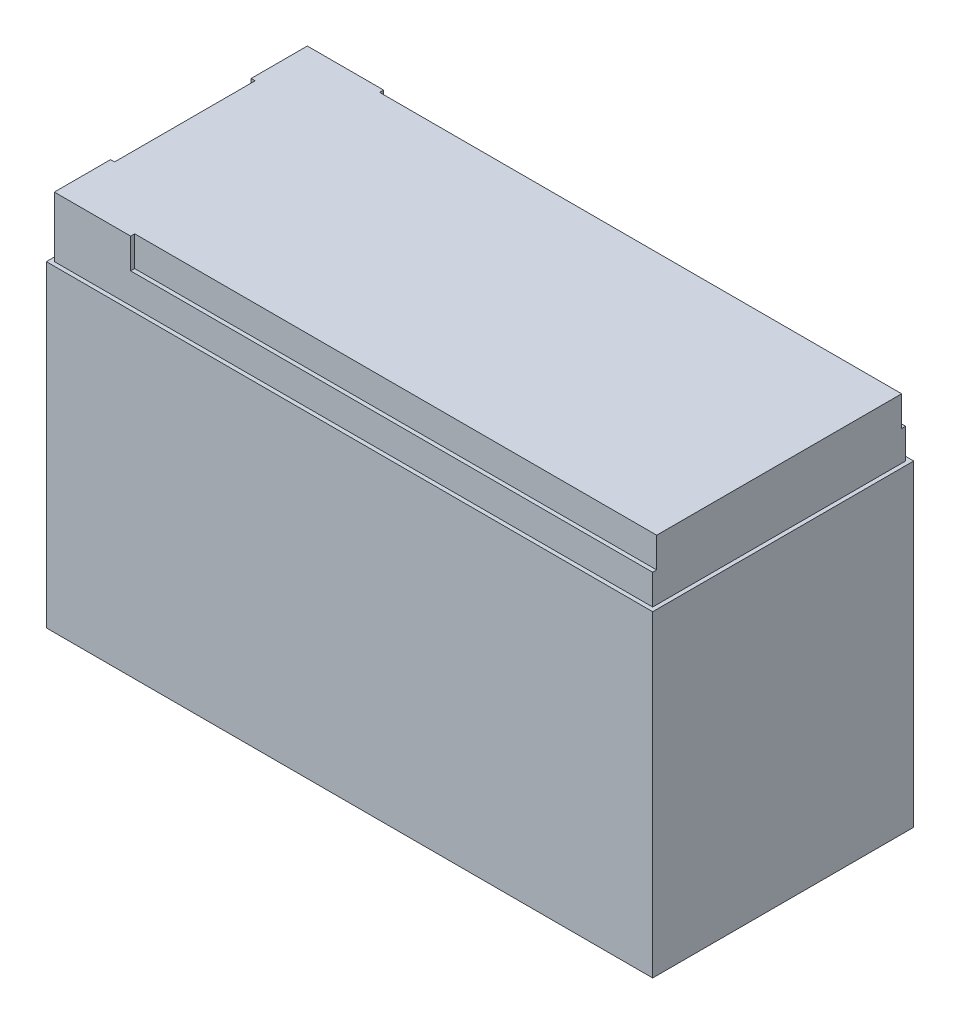
from build123d import *

# Parameters (mm, degrees)
SKETCH1_W           = 151
SKETCH1_H           = 65
BOSS_EXTRUDE1_DEPTH = 94
SKETCH2_W           = 151
SKETCH2_H           = 65
SKETCH2_W_2         = 149
SKETCH2_H_2         = 63
CUT_EXTRUDE1_DEPTH  = 15
SKETCH3_W           = 130
SKETCH3_H           = 1
CUT_EXTRUDE2_DEPTH  = 7.5
SKETCH4_W           = 1
SKETCH4_H           = 35
CUT_EXTRUDE3_DEPTH  = 7.5


with BuildPart() as part:
    # Sketch1 → Boss-Extrude1 (new body)
    with BuildSketch(Plane(origin=(0, 0, 0), x_dir=(1, 0, 0), z_dir=(0, 1, 0))):
        Rectangle(SKETCH1_W, SKETCH1_H)
    extrude(amount=BOSS_EXTRUDE1_DEPTH)

    # Sketch2 → Cut-Extrude1 (cut)
    with BuildSketch(Plane(origin=(0, 94, 0), x_dir=(1, 0, 0), z_dir=(0, 1, 0))):
        Rectangle(SKETCH2_W, SKETCH2_H)
        Rectangle(SKETCH2_W_2, SKETCH2_H_2, mode=Mode.SUBTRACT)
    extrude(amount=-CUT_EXTRUDE1_DEPTH, mode=Mode.SUBTRACT)

    # Sketch3 → Cut-Extrude2 (cut)
    with BuildSketch(Plane(origin=(0, 94, 0), x_dir=(1, 0, 0), z_dir=(0, 1, 0))):
        with Locations((9.5, 31)):
            Rectangle(SKETCH3_W, SKETCH3_H)
        with Locations((9.5, -31)):
            Rectangle(SKETCH3_W, SKETCH3_H)
    extrude(amount=-CUT_EXTRUDE2_DEPTH, mode=Mode.SUBTRACT)

    # Sketch4 → Cut-Extrude3 (cut)
    with BuildSketch(Plane(origin=(0, 94, 0), x_dir=(1, 0, 0), z_dir=(0, 1, 0))):
        with Locations((-74, 0)):
            Rectangle(SKETCH4_W, SKETCH4_H)
    extrude(amount=-CUT_EXTRUDE3_DEPTH, mode=Mode.SUBTRACT)


solid = part.part
